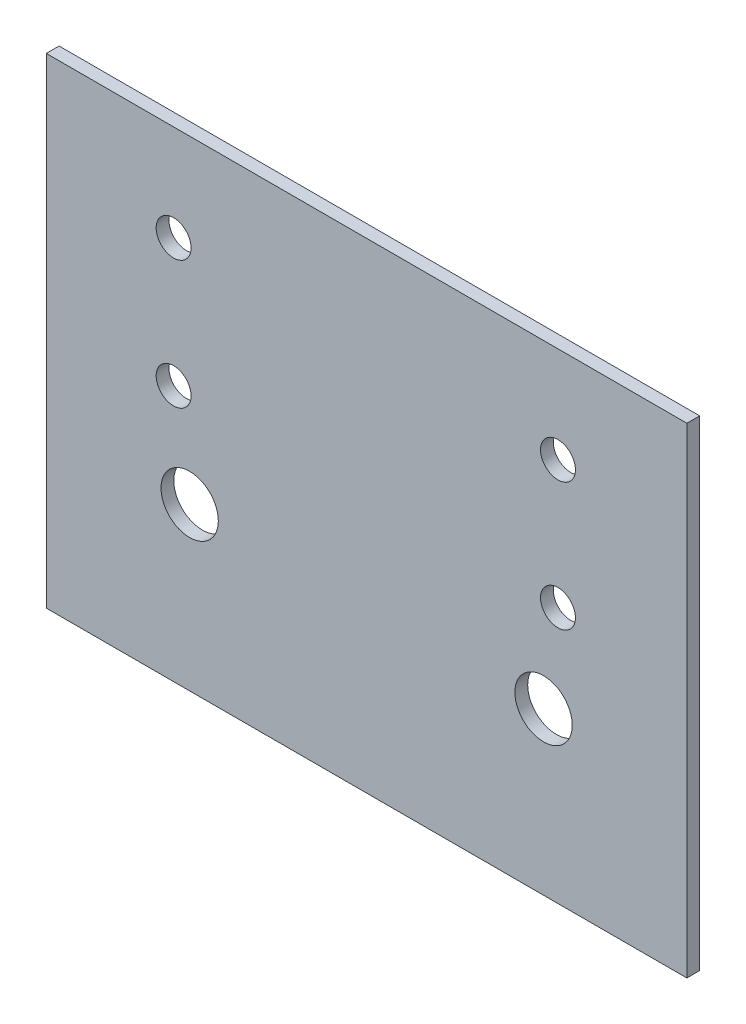
from build123d import *

# Parameters (mm, degrees)
SKETCH_1_W      = 400
SKETCH_1_H      = 300
SKETCH_1_R      = 10.9
SKETCH_1_R_2    = 17.9
EXTRUDE_1_DEPTH = 8


with BuildPart() as part:
    # 草图1 → 凸台-拉伸1 (new body)
    with BuildSketch(Plane.XY):
        with Locations((144.893890631, -115.797373506)):
            Rectangle(SKETCH_1_W, SKETCH_1_H)
        with Locations((24.397869229, -25.797373506)):
            Circle(SKETCH_1_R, mode=Mode.SUBTRACT)
        with Locations((264.397869229, -25.797373506)):
            Circle(SKETCH_1_R, mode=Mode.SUBTRACT)
        with Locations((24.397869229, -105.797373506)):
            Circle(SKETCH_1_R, mode=Mode.SUBTRACT)
        with Locations((264.397869229, -105.797373506)):
            Circle(SKETCH_1_R, mode=Mode.SUBTRACT)
        with Locations((34.397869229, -164.958171337)):
            Circle(SKETCH_1_R_2, mode=Mode.SUBTRACT)
        with Locations((255.389912033, -164.958171337)):
            Circle(SKETCH_1_R_2, mode=Mode.SUBTRACT)
    extrude(amount=EXTRUDE_1_DEPTH)


solid = part.part
